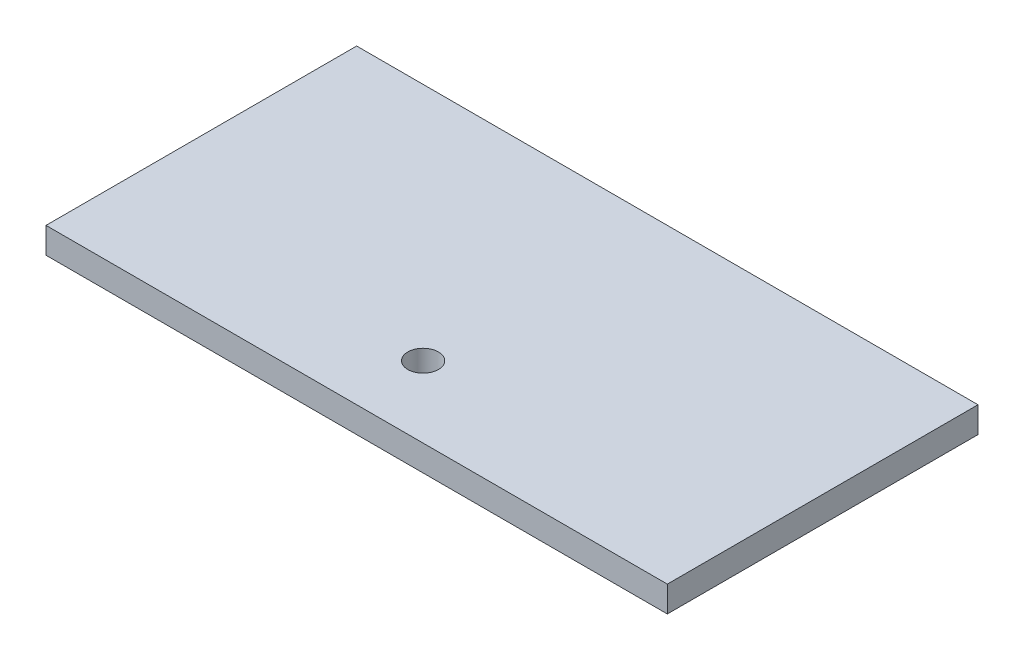
from build123d import *

# Parameters (mm, degrees)
SKETCH1_W           = 609.6
SKETCH1_H           = 304.8
BOSS_EXTRUDE1_DEPTH = 25.4
SKETCH2_R           = 15
CUT_EXTRUDE1_DEPTH  = 25.4


with BuildPart() as part:
    # Sketch1 → Boss-Extrude1 (new body)
    with BuildSketch(Plane(origin=(0, 0, 0), x_dir=(1, 0, 0), z_dir=(0, 1, 0))):
        with Locations((304.8, 152.4)):
            Rectangle(SKETCH1_W, SKETCH1_H)
    extrude(amount=BOSS_EXTRUDE1_DEPTH)

    # Sketch2 → Cut-Extrude1 (cut)
    with BuildSketch(Plane(origin=(0, 25.4, 0), x_dir=(1, 0, 0), z_dir=(0, 1, 0))):
        with Locations((300, 70)):
            Circle(SKETCH2_R)
    extrude(amount=-CUT_EXTRUDE1_DEPTH, mode=Mode.SUBTRACT)


solid = part.part
